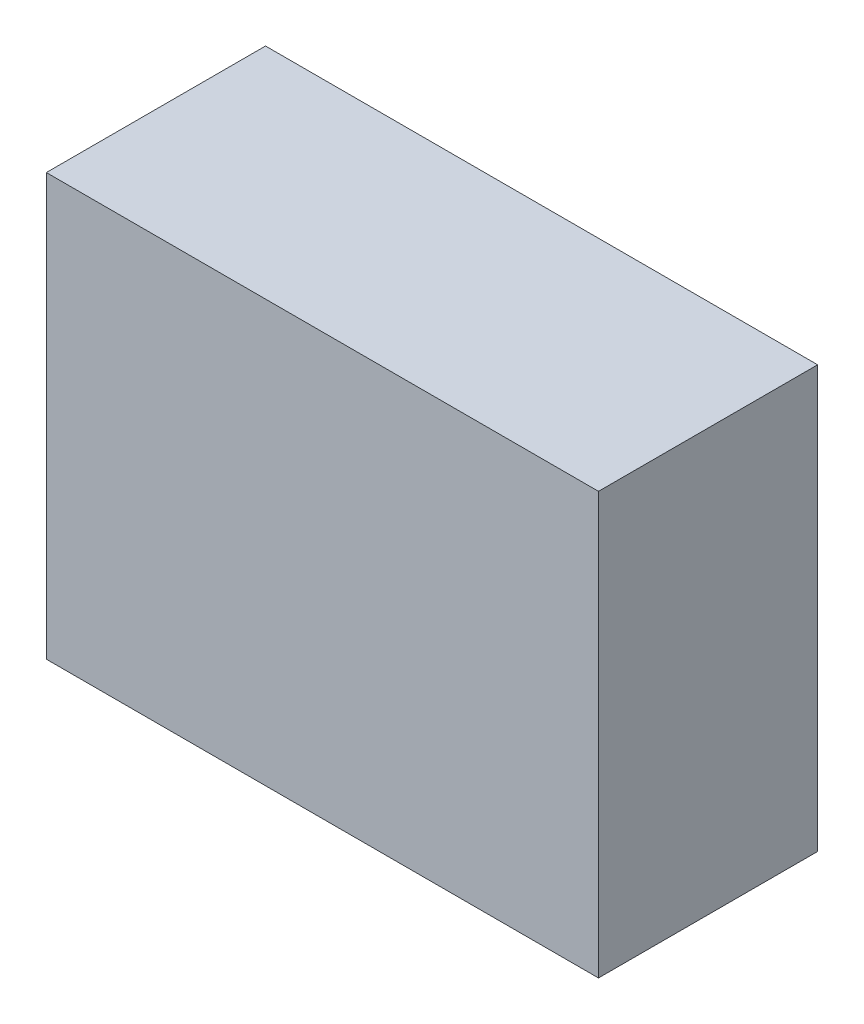
from build123d import *

# Parameters (mm, degrees)
SKETCH1_W           = 131
SKETCH1_H           = 100
BOSS_EXTRUDE1_DEPTH = 52


with BuildPart() as part:
    # Sketch1 → Boss-Extrude1 (new body)
    with BuildSketch(Plane.XY):
        Rectangle(SKETCH1_W, SKETCH1_H)
    extrude(amount=BOSS_EXTRUDE1_DEPTH)


solid = part.part
